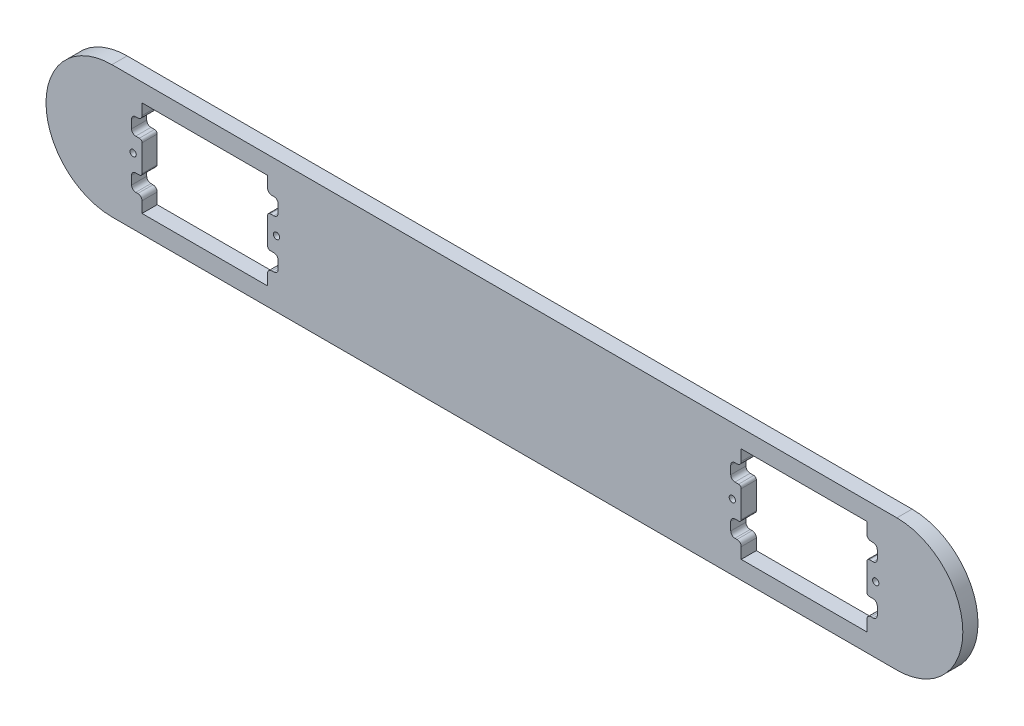
from build123d import *

# Parameters (mm, degrees)
SKETCH_1_R          = 0.6
SKETCH_1_W          = 24
SKETCH_1_H          = 12.5
EXTRUDE_1_DEPTH     = 1.45
CUT_EXTRUDE_1_DEPTH = 3
FILLET_1_R          = 0.5


with BuildPart() as part:
    # 草图1 → 凸台-拉伸1 (new body, symmetric)
    with BuildSketch(Plane.XY):
        with BuildLine():
            Line((-75, 12.6), (75, 12.6))
            ThreePointArc((75, 12.6), (87.6, 0), (75, -12.6))
            Line((75, -12.6), (-75, -12.6))
            ThreePointArc((-75, -12.6), (-87.6, 0), (-75, 12.6))
        make_face()
        with Locations((-43.55, 0)):
            Circle(SKETCH_1_R, mode=Mode.SUBTRACT)
        with Locations((-70.95, 0)):
            Circle(SKETCH_1_R, mode=Mode.SUBTRACT)
        with Locations((70.95, 0)):
            Circle(SKETCH_1_R, mode=Mode.SUBTRACT)
        with Locations((43.55, 0)):
            Circle(SKETCH_1_R, mode=Mode.SUBTRACT)
        with Locations((-57.25, 0)):
            Rectangle(SKETCH_1_W, SKETCH_1_H, mode=Mode.SUBTRACT)
        with Locations((57.25, 0)):
            Rectangle(SKETCH_1_W, SKETCH_1_H, mode=Mode.SUBTRACT)
    extrude(amount=EXTRUDE_1_DEPTH, both=True)

    # 草图2 → 切除-拉伸1 (cut)
    with BuildSketch(Plane.XY.offset(1.45)):
        with BuildLine():
            Line((44.45, 6.25), (44.05, 6.25))
            ThreePointArc((44.05, 6.25), (43.484314575, 6.015685425), (43.25, 5.45))
            Line((43.25, 5.45), (43.25, 3.85))
            ThreePointArc((43.25, 3.85), (43.484314575, 3.284314575), (44.05, 3.05))
            Line((44.05, 3.05), (45.25, 3.05))
            Line((45.25, 3.05), (45.25, 6.25))
            Line((45.25, 6.25), (69.25, 6.25))
            Line((69.25, 6.25), (69.25, 3.05))
            Line((69.25, 3.05), (70.45, 3.05))
            ThreePointArc((70.45, 3.05), (71.015685425, 3.284314575), (71.25, 3.85))
            Line((71.25, 3.85), (71.25, 5.45))
            ThreePointArc((71.25, 5.45), (71.015685425, 6.015685425), (70.45, 6.25))
            Line((70.45, 6.25), (70.05, 6.25))
            ThreePointArc((70.05, 6.25), (69.484314575, 6.484314575), (69.25, 7.05))
            Line((69.25, 7.05), (69.25, 9.15))
            Line((69.25, 9.15), (45.25, 9.15))
            Line((45.25, 9.15), (45.25, 7.05))
            ThreePointArc((45.25, 7.05), (45.015685425, 6.484314575), (44.45, 6.25))
        make_face()
        with BuildLine():
            Line((44.05, -3.05), (45.25, -3.05))
            Line((45.25, -3.05), (45.25, -6.25))
            Line((45.25, -6.25), (69.25, -6.25))
            Line((69.25, -6.25), (69.25, -3.05))
            Line((69.25, -3.05), (70.45, -3.05))
            ThreePointArc((70.45, -3.05), (71.015685425, -3.284314575), (71.25, -3.85))
            Line((71.25, -3.85), (71.25, -5.45))
            ThreePointArc((71.25, -5.45), (71.015685425, -6.015685425), (70.45, -6.25))
            Line((70.45, -6.25), (70.05, -6.25))
            ThreePointArc((70.05, -6.25), (69.484314575, -6.484314575), (69.25, -7.05))
            Line((69.25, -7.05), (69.25, -9.15))
            Line((69.25, -9.15), (45.25, -9.15))
            Line((45.25, -9.15), (45.25, -7.05))
            ThreePointArc((45.25, -7.05), (45.015685425, -6.484314575), (44.45, -6.25))
            Line((44.45, -6.25), (44.05, -6.25))
            ThreePointArc((44.05, -6.25), (43.484314575, -6.015685425), (43.25, -5.45))
            Line((43.25, -5.45), (43.25, -3.85))
            ThreePointArc((43.25, -3.85), (43.484314575, -3.284314575), (44.05, -3.05))
        make_face()
        with BuildLine():
            Line((-45.25, 3.05), (-45.25, 6.25))
            Line((-45.25, 6.25), (-69.25, 6.25))
            Line((-69.25, 6.25), (-69.25, 3.05))
            Line((-69.25, 3.05), (-70.45, 3.05))
            ThreePointArc((-70.45, 3.05), (-71.015685425, 3.284314575), (-71.25, 3.85))
            Line((-71.25, 3.85), (-71.25, 5.45))
            ThreePointArc((-71.25, 5.45), (-71.015685425, 6.015685425), (-70.45, 6.25))
            Line((-70.45, 6.25), (-70.05, 6.25))
            ThreePointArc((-70.05, 6.25), (-69.484314575, 6.484314575), (-69.25, 7.05))
            Line((-69.25, 7.05), (-69.25, 9.15))
            Line((-69.25, 9.15), (-45.25, 9.15))
            Line((-45.25, 9.15), (-45.25, 7.05))
            ThreePointArc((-45.25, 7.05), (-45.015685425, 6.484314575), (-44.45, 6.25))
            Line((-44.45, 6.25), (-44.05, 6.25))
            ThreePointArc((-44.05, 6.25), (-43.484314575, 6.015685425), (-43.25, 5.45))
            Line((-43.25, 5.45), (-43.25, 3.85))
            ThreePointArc((-43.25, 3.85), (-43.484314575, 3.284314575), (-44.05, 3.05))
            Line((-44.05, 3.05), (-45.25, 3.05))
        make_face()
        with BuildLine():
            Line((-45.25, -7.05), (-45.25, -9.15))
            Line((-45.25, -9.15), (-69.25, -9.15))
            Line((-69.25, -9.15), (-69.25, -7.05))
            ThreePointArc((-69.25, -7.05), (-69.484314575, -6.484314575), (-70.05, -6.25))
            Line((-70.05, -6.25), (-70.45, -6.25))
            ThreePointArc((-70.45, -6.25), (-71.015685425, -6.015685425), (-71.25, -5.45))
            Line((-71.25, -5.45), (-71.25, -3.85))
            ThreePointArc((-71.25, -3.85), (-71.015685425, -3.284314575), (-70.45, -3.05))
            Line((-70.45, -3.05), (-69.25, -3.05))
            Line((-69.25, -3.05), (-69.25, -6.25))
            Line((-69.25, -6.25), (-45.25, -6.25))
            Line((-45.25, -6.25), (-45.25, -3.05))
            Line((-45.25, -3.05), (-44.05, -3.05))
            ThreePointArc((-44.05, -3.05), (-43.484314575, -3.284314575), (-43.25, -3.85))
            Line((-43.25, -3.85), (-43.25, -5.45))
            ThreePointArc((-43.25, -5.45), (-43.484314575, -6.015685425), (-44.05, -6.25))
            Line((-44.05, -6.25), (-44.45, -6.25))
            ThreePointArc((-44.45, -6.25), (-45.015685425, -6.484314575), (-45.25, -7.05))
        make_face()
    extrude(amount=-CUT_EXTRUDE_1_DEPTH, mode=Mode.SUBTRACT)

    # 圆角1
    fillet_1_edges = [part.edges().sort_by_distance(p)[0] for p in [
        (69.25, -3.05, 0),
        (-69.25, 3.05, 0),
        (45.25, -3.05, 0),
        (-45.25, 3.05, 0),
        (-45.25, -3.05, 0),
        (-69.25, -3.05, 0),
        (69.25, 3.05, 0),
        (45.25, 3.05, 0),
    ]]
    fillet(fillet_1_edges, radius=FILLET_1_R)


solid = part.part
